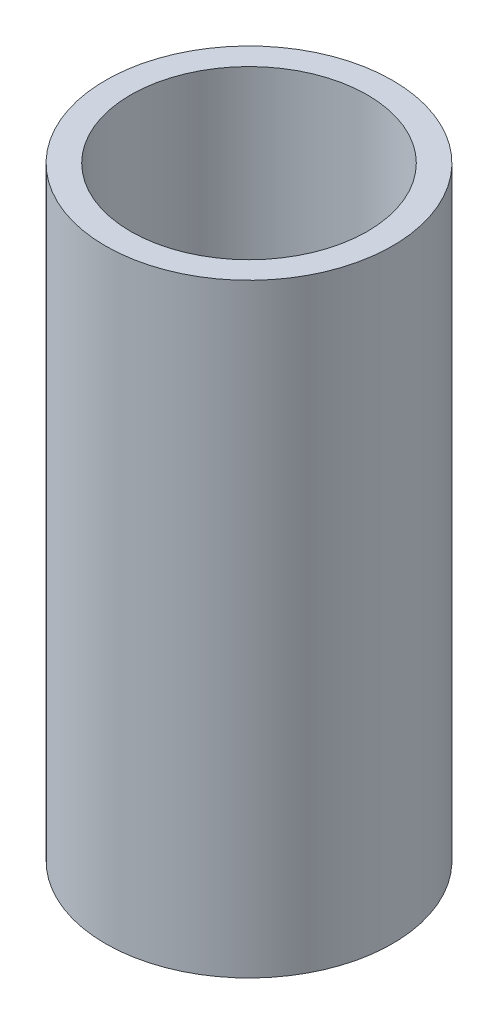
from build123d import *

# Parameters (mm, degrees)
ESQUISSE1_R        = 2.85
ESQUISSE1_R_2      = 2.35
BOSS_EXTRU_1_DEPTH = 12


with BuildPart() as part:
    # Esquisse1 → Boss.-Extru.1 (new body)
    with BuildSketch(Plane(origin=(0, 0, 0), x_dir=(1, 0, 0), z_dir=(0, 1, 0))):
        Circle(ESQUISSE1_R)
        Circle(ESQUISSE1_R_2, mode=Mode.SUBTRACT)
    extrude(amount=BOSS_EXTRU_1_DEPTH)


solid = part.part
